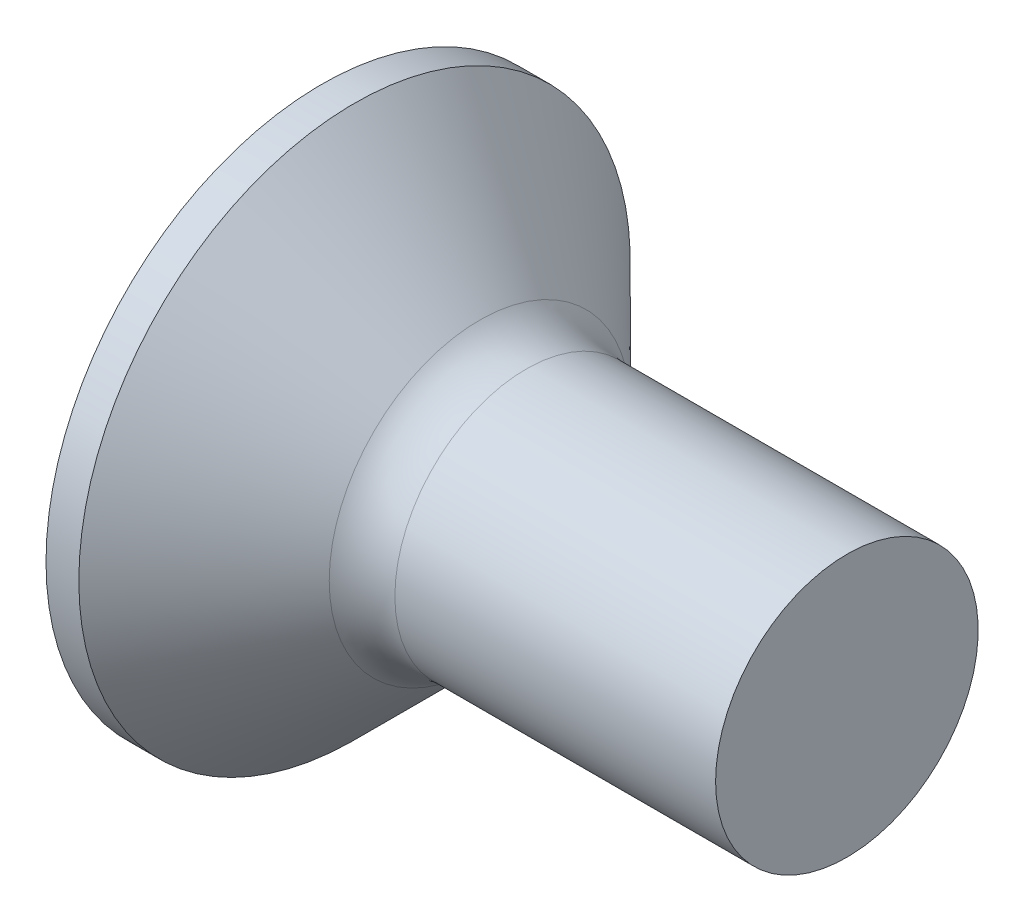
from build123d import *

# Parameters (mm, degrees)
FILLET1_R    = 1
SKETCH3_W    = 1.03
SKETCH3_H    = 4.4
SKETCH4_W    = 1.03
SKETCH4_H    = 1.897120746
RECPAT_COUNT = 2
RECPAT_ANGLE = 90


with BuildPart() as part:
    # BodySke → Base-Revolve (revolve)
    with BuildSketch(Plane.XY):
        Polygon((0, 0), (0, 4.2), (0.5, 4.2), (2.7, 2), (8, 2), (8, 0), align=None)
    revolve(axis=Axis((-6.35, 0, 0), (1, 0, 0)))

    # Fillet1
    fillet1_edges = [part.edges().sort_by_distance(p)[0] for p in [
        (2.7, -2, 0),
    ]]
    fillet(fillet1_edges, radius=FILLET1_R)

    # Sketch3 → Recess section 0
    with BuildSketch(Plane.ZY):
        Rectangle(SKETCH3_W, SKETCH3_H)
    # Sketch4 → Recess section 1
    with BuildSketch(Plane.ZY.offset(-2.51)):
        Rectangle(SKETCH4_W, SKETCH4_H)
    recess = loft(mode=Mode.SUBTRACT)

    # RecPat: Recess ×2 about axis
    recpat_axis = Axis((0, 0, 0), (1, 0, 0))
    for i in range(1, RECPAT_COUNT):
        add(recess.rotate(recpat_axis, i * RECPAT_ANGLE / (RECPAT_COUNT - 1)), mode=Mode.SUBTRACT)

    # RecCorSke → RecessCore (revolve, cut)
    with BuildSketch(Plane.XY):
        Polygon((0, 0), (0, 1.026516298), (2.51, 0.851), (2.786506661, 0), align=None)
    revolve(axis=Axis((-3.175, 0, 0), (1, 0, 0)), mode=Mode.SUBTRACT)


solid = part.part
